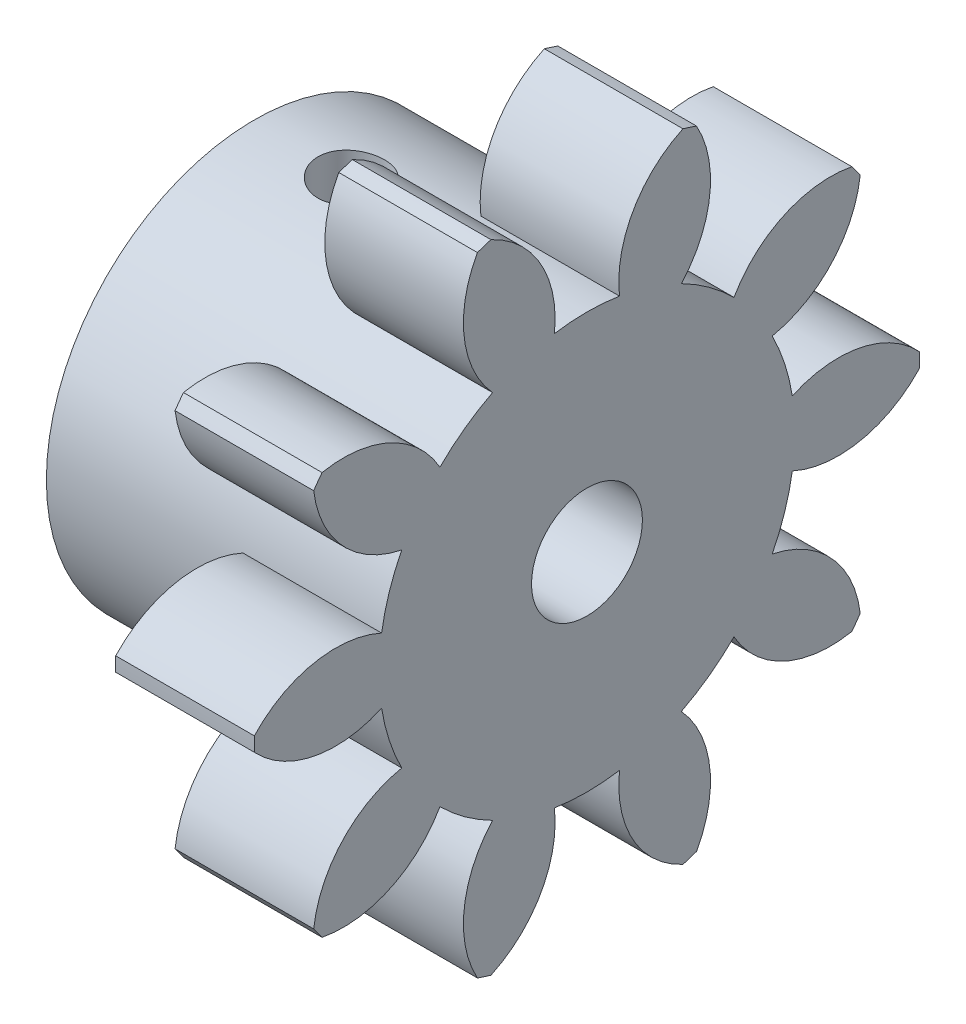
from build123d import *
from build123d.topology import SkipClean

# Parameters (mm, degrees)
BASPROSKE_W                  = 10
BASPROSKE_H                  = 12
TOOTHCUT_DEPTH               = 20.697715604
TEETHCUTS_COUNT              = 10
TEETHCUTS_ANGLE              = 324
HUBNEAONESKE_R               = 7.499
HUBNEARONE_DEPTH             = 10.0000508
BORSKE_R                     = 2
BORE_DEPTH                   = 20.0000508
ESQUISSE1_W                  = 4
ESQUISSE1_H                  = 1.5
ENL_V_MAT_EXTRU_1_DEPTH      = 10
ESQUISSE8_R                  = 7.499
ENL_V_MAT_EXTRU_4_DEPTH      = 3
ENL_V_MAT_EXTRU_2_REACH      = 23.823
ENL_V_MAT_EXTRU_2_END_RADIUS = 7.499
ESQUISSE6_R                  = 1.2
ESQUISSE7_R                  = 12
ENL_V_MAT_EXTRU_3_DEPTH      = 5


with BuildPart() as part:
    # BasProSke → Base-Revolve (revolve)
    with BuildSketch(Plane(origin=(0, 0, 0), x_dir=(1, 0, 0), z_dir=(0, 1, 0)), mode=Mode.PRIVATE) as base_revolve_sk:
        with Locations((5, 6)):
            Rectangle(BASPROSKE_W, BASPROSKE_H)
    revolve(base_revolve_sk.sketch.rotate(Axis((-10, 0, 0), (1, 0, 0)), 180), axis=Axis((-10, 0, 0), (1, 0, 0)))

    # TooCutSke → ToothCut (cut, through all)
    with BuildSketch(Plane(origin=(0, 0, 0), x_dir=(0, 0, -1), z_dir=(1, 0, 0))):
        with BuildLine():
            ThreePointArc((1.173662691, 7.406586048), (0, 7.499), (-1.173662691, 7.406586048))
            ThreePointArc((-1.173662691, 7.406586048), (-1.668191438, 9.834565786), (-3.497907776, 11.50542856))
            ThreePointArc((-3.497907776, 11.50542856), (0, 12.0254), (3.497907776, 11.50542856))
            ThreePointArc((3.497907776, 11.50542856), (1.668191438, 9.834565786), (1.173662691, 7.406586048))
        make_face()
    toothcut = extrude(amount=TOOTHCUT_DEPTH, mode=Mode.SUBTRACT)

    # TeethCuts: ToothCut ×10 about axis
    teethcuts_axis = Axis((-10, 0, 0), (1, 0, 0))
    for i in range(1, TEETHCUTS_COUNT):
        add(toothcut.rotate(teethcuts_axis, i * TEETHCUTS_ANGLE / (TEETHCUTS_COUNT - 1)), mode=Mode.SUBTRACT)

    # HubNeaOneSke → HubNearOne (add)
    with SkipClean():  # the faces are left unmerged after this step: merging them gives an invalid solid
        with BuildSketch(Plane.ZY):
            Circle(HUBNEAONESKE_R)
        extrude(amount=HUBNEARONE_DEPTH)

    # BorSke → Bore (cut, symmetric)
    with SkipClean():  # the faces are left unmerged after this step: merging them gives an invalid solid
        with BuildSketch(Plane(origin=(0, 0, 0), x_dir=(0, 0, -1), z_dir=(1, 0, 0))):
            with Locations(Location((0, 0, 0), (0, 0, 180))):
                Circle(BORSKE_R)
        extrude(amount=BORE_DEPTH, both=True, mode=Mode.SUBTRACT)

    # Esquisse1 → Enlèv. mat.-Extru.1 (cut)
    with SkipClean():  # the faces are left unmerged after this step: merging them gives an invalid solid
        with BuildSketch(Plane.ZY.offset(10.0000508)):
            with Locations((0, 4.5)):
                Rectangle(ESQUISSE1_W, ESQUISSE1_H)
        extrude(amount=-ENL_V_MAT_EXTRU_1_DEPTH, mode=Mode.SUBTRACT)

    # Esquisse8 → Enlèv. mat.-Extru.4 (cut)
    with SkipClean():  # the faces are left unmerged after this step: merging them gives an invalid solid
        with BuildSketch(Plane.ZY.offset(10.0000508)):
            Circle(ESQUISSE8_R)
        extrude(amount=-ENL_V_MAT_EXTRU_4_DEPTH, mode=Mode.SUBTRACT)

    # Esquisse4 → Dégagement M21 (revolve, cut)
    with SkipClean():  # the faces are left unmerged after this step: merging them gives an invalid solid
        with BuildSketch(Plane(origin=(-3.5000508, 3.75, 0), x_dir=(0, 0, 1), z_dir=(1, 0, 0))):
            Polygon((0, 0), (0, 3.721032743), (1.2, 3), (1.2, 0), align=None)
        revolve(axis=Axis((-3.5000508, 10.1, 0), (0, -1, 0)), mode=Mode.SUBTRACT)

    # Enlèv. mat.-Extru.2: up to this cylinder (the profile starts inside it)
    with SkipClean():  # the faces are left unmerged after this step: merging them gives an invalid solid
        enl_v_mat_extru_2_end = Plane(origin=(-3.500051, 0, 0), z_dir=(-1, 0, 0)) * Cylinder(ENL_V_MAT_EXTRU_2_END_RADIUS, 63.644, mode=Mode.PRIVATE)
        # Esquisse6 → Enlèv. mat.-Extru.2 (cut, up to the surface)
        with BuildSketch(Plane(origin=(0, 3.75, 0), x_dir=(-1, 0, 0), z_dir=(0, 1, 0)), mode=Mode.PRIVATE) as enl_v_mat_extru_2_sk1:
            with Locations(Location((3.5000508, 0, 0), (0, 0, 90))):
                Circle(ESQUISSE6_R)
        enl_v_mat_extru_2_tool1 = extrude(enl_v_mat_extru_2_sk1.sketch, amount=ENL_V_MAT_EXTRU_2_REACH, mode=Mode.PRIVATE) & enl_v_mat_extru_2_end
        add(enl_v_mat_extru_2_tool1.solids().sort_by_distance((-3.500051, 3.75, 0))[0], mode=Mode.SUBTRACT)

    # Esquisse7 → Enlèv. mat.-Extru.3 (cut)
    with SkipClean():  # the faces are left unmerged after this step: merging them gives an invalid solid
        with BuildSketch(Plane(origin=(10, 0, 0), x_dir=(0, 0, -1), z_dir=(1, 0, 0))):
            Circle(ESQUISSE7_R)
        extrude(amount=-ENL_V_MAT_EXTRU_3_DEPTH, mode=Mode.SUBTRACT)


solid = part.part
